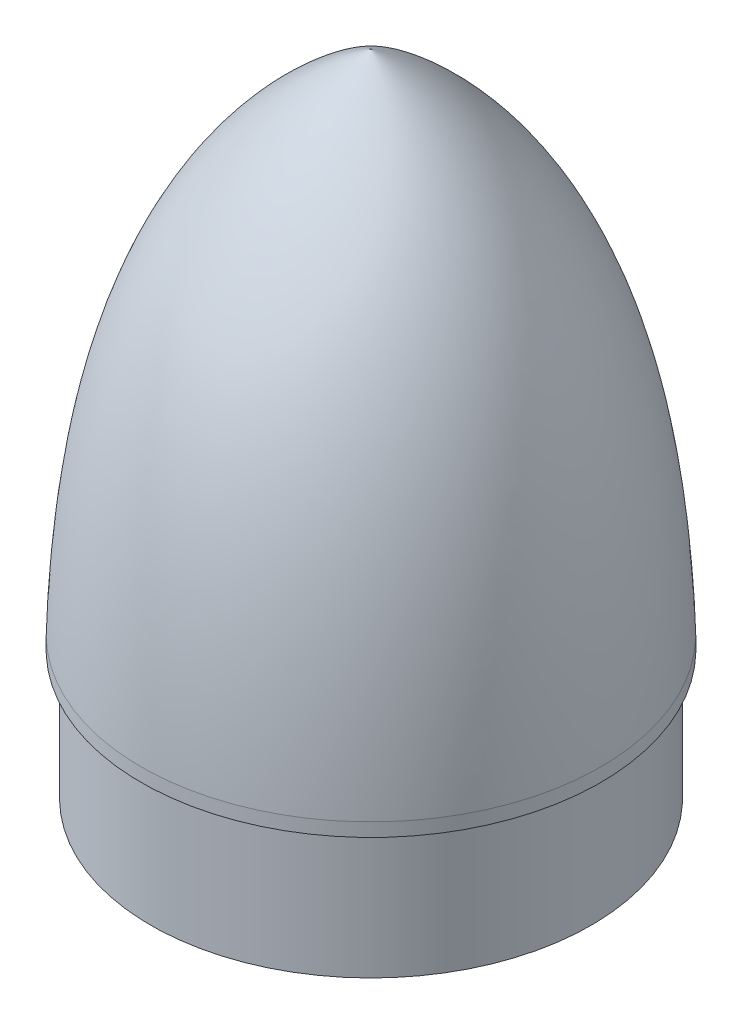
from build123d import *


with BuildPart() as part:
    # Sketch1 → Revolve1 (revolve)
    with BuildSketch(Plane.XY):
        with BuildLine():
            Line((-13.332366867, 13.177419355), (-13.332366867, -5.822580645))
            Line((-13.332366867, -5.822580645), (-12.332366867, -5.822580645))
            Line((-12.332366867, -5.822580645), (-12.332366867, 15.177419355))
            Line((-12.332366867, 15.177419355), (-10.344271679, 32.852989069))
            Line((-10.344271679, 32.852989069), (-6.874157706, 48.815513341))
            Line((-6.874157706, 48.815513341), (-2.015998145, 63.563497723))
            Line((-2.015998145, 63.563497723), (10.991173398, 79.725511747))
            Line((10.991173398, 79.725511747), (19.267633133, 86.988176056))
            Line((19.267633133, 86.988176056), (19.267633133, 90.177419355))
            add(Edge.make_bspline(
                [(19.267633133, 90.177419355), (-8.310711892, 74.843338049), (-13.761600321, 43.164318334), (-14.732366867, 15.177419355)],
                knots=[0, 0, 0, 0, 1, 1, 1, 1], degree=3))
            Line((-14.732366867, 15.177419355), (-14.732366867, 13.177419355))
            Line((-14.732366867, 13.177419355), (-13.332366867, 13.177419355))
        make_face()
    revolve(axis=Axis((19.267633133, 86.988176056, 0), (0, 1, 0)))


solid = part.part
